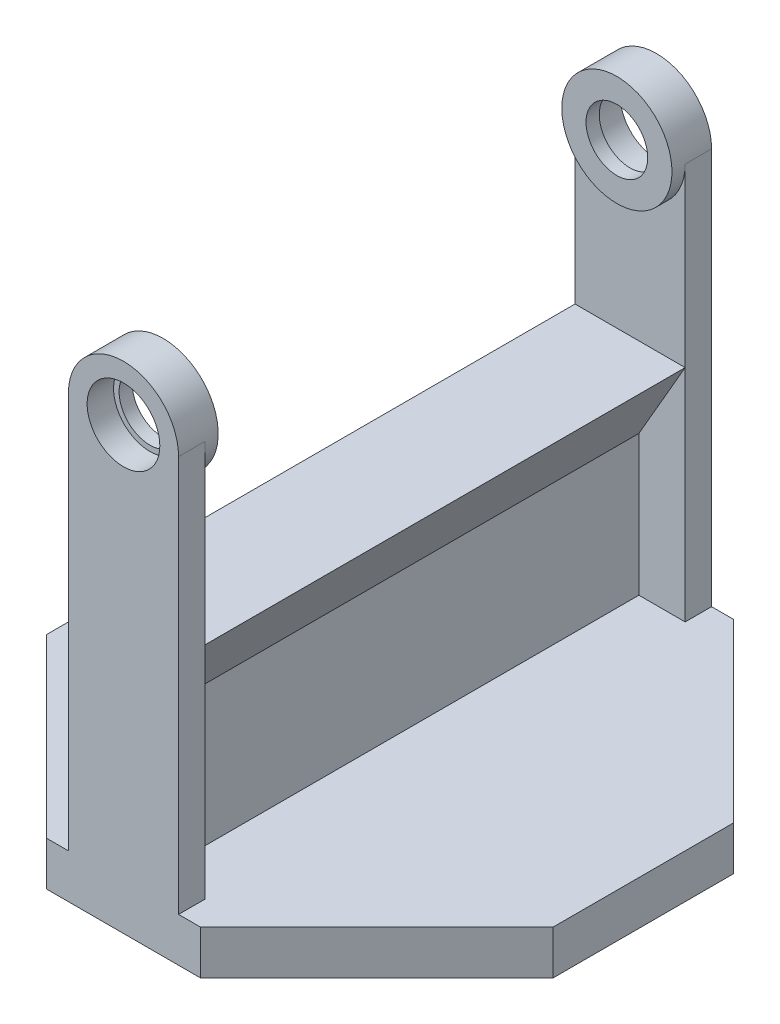
from build123d import *

# Parameters (mm, degrees)
SKETCH1_W           = 115
SKETCH1_H           = 121
BOSS_EXTRUDE1_DEPTH = 10
BOSS_EXTRUDE2_DEPTH = 6
SKETCH3_R           = 12.5
SKETCH3_R_2         = 7
BOSS_EXTRUDE3_DEPTH = 3
SKETCH4_R           = 8.25
CUT_EXTRUDE1_DEPTH  = 6
SKETCH6_W           = 54.5
SKETCH6_H           = 50
BOSS_EXTRUDE5_DEPTH = 2
BOSS_EXTRUDE6_REACH = 117
CHAMFER1_SIZE       = 40


with BuildPart() as part:
    # Sketch1 → Boss-Extrude1 (new body)
    with BuildSketch(Plane(origin=(0, 0, 0), x_dir=(1, 0, 0), z_dir=(0, 1, 0))):
        Rectangle(SKETCH1_W, SKETCH1_H)
    extrude(amount=BOSS_EXTRUDE1_DEPTH)

    # Sketch2 → Boss-Extrude2 (add)
    with BuildSketch(Plane.XY.offset(60.5)):
        with BuildLine():
            Line((-12.5, 100), (-12.5, 0))
            Line((-12.5, 0), (12.5, 0))
            Line((12.5, 0), (12.5, 100))
            ThreePointArc((12.5, 100), (0, 112.5), (-12.5, 100))
        make_face()
    boss_extrude2 = extrude(amount=-BOSS_EXTRUDE2_DEPTH)

    # Sketch3 → Boss-Extrude3 (add)
    with BuildSketch(Plane(origin=(0, 0, 54.5), x_dir=(-1, 0, 0), z_dir=(0, 0, -1))):
        with Locations((0, 100)):
            Circle(SKETCH3_R)
        with Locations((0, 100)):
            Circle(SKETCH3_R_2, mode=Mode.SUBTRACT)
    boss_extrude3 = extrude(amount=BOSS_EXTRUDE3_DEPTH)

    # Sketch4 → Cut-Extrude1 (cut)
    with BuildSketch(Plane.XY.offset(60.5)):
        with Locations((0, 100)):
            Circle(SKETCH4_R)
    cut_extrude1 = extrude(amount=-CUT_EXTRUDE1_DEPTH, mode=Mode.SUBTRACT)

    # Sketch6 → Boss-Extrude5 (add, symmetric)
    with BuildSketch(Plane(origin=(0, 0, 0), x_dir=(0, 0, -1), z_dir=(1, 0, 0))):
        with Locations((-27.25, 35)):
            Rectangle(SKETCH6_W, SKETCH6_H)
    boss_extrude5 = extrude(amount=BOSS_EXTRUDE5_DEPTH, both=True)

    # Mirror1: Boss-Extrude2, Boss-Extrude3, Cut-Extrude1, Boss-Extrude5 across plane
    add(boss_extrude2.mirror(Plane.XY))
    add(boss_extrude3.mirror(Plane.XY))
    add(cut_extrude1.mirror(Plane.XY), mode=Mode.SUBTRACT)
    add(boss_extrude5.mirror(Plane.XY))

    # Sketch7 → Boss-Extrude6 (add, up to next)
    with BuildSketch(Plane.XY.offset(-54.5), mode=Mode.PRIVATE) as boss_extrude6_sk1:
        Polygon((2, 60), (12.5, 60), (2, 41.813466521), align=None)
    boss_extrude6_tool1 = extrude(boss_extrude6_sk1.sketch, amount=BOSS_EXTRUDE6_REACH, mode=Mode.PRIVATE) - part.part
    add(boss_extrude6_tool1.solids().sort_by_distance((5.5, 53.937822, -54.5))[0])
    # Sketch7 → Boss-Extrude6 (add, up to next)
    with BuildSketch(Plane.XY.offset(-54.5), mode=Mode.PRIVATE) as boss_extrude6_sk2:
        Polygon((-2, 60), (-12.5, 60), (-2, 41.813466521), align=None)
    boss_extrude6_tool2 = extrude(boss_extrude6_sk2.sketch, amount=BOSS_EXTRUDE6_REACH, mode=Mode.PRIVATE) - part.part
    add(boss_extrude6_tool2.solids().sort_by_distance((-5.5, 53.937822, -54.5))[0])

    # Chamfer1
    chamfer1_edges = [part.edges().sort_by_distance(p)[0] for p in [
        (57.5, 5, 60.5),
        (-57.5, 5, 60.5),
        (-57.5, 5, -60.5),
        (57.5, 5, -60.5),
    ]]
    chamfer(chamfer1_edges, length=CHAMFER1_SIZE)


solid = part.part
